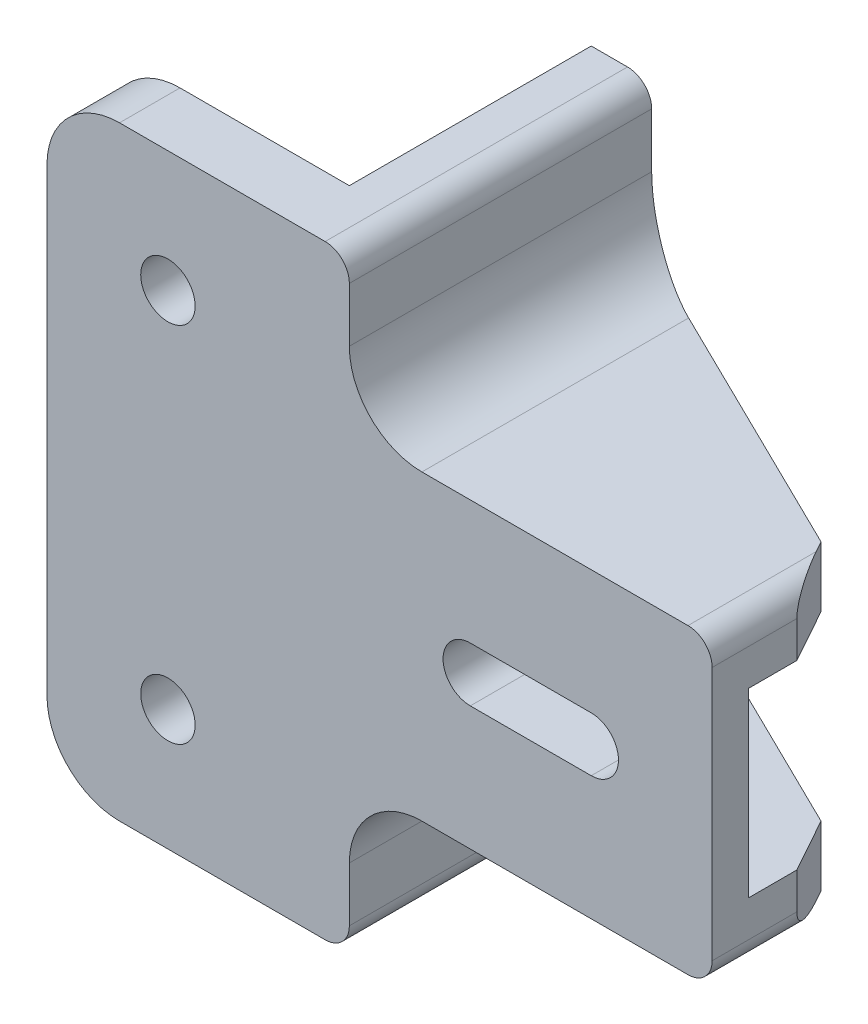
from build123d import *

# Parameters (mm, degrees)
BOSS_EXTRUDE1_DEPTH = 5
SKETCH2_R           = 2.25
CUT_EXTRUDE1_DEPTH  = 6
SKETCH3_W           = 5
SKETCH3_H           = 50
BOSS_EXTRUDE2_DEPTH = 20
SKETCH4_R           = 2.25
CUT_EXTRUDE2_DEPTH  = 36
SKETCH5_W           = 20
SKETCH5_H           = 5
BOSS_EXTRUDE3_DEPTH = 30
CUT_EXTRUDE3_DEPTH  = 38.5
FILLET1_R           = 6
CHAMFER1_SIZE       = 2
FILLET2_R           = 6
FILLET3_R           = 2


with BuildPart() as part:
    # Sketch1 → Boss-Extrude1 (new body)
    with BuildSketch(Plane.XY):
        Polygon((0, 25), (0, 0), (-30, 0), (-30, -12.5), (-55, -12.5), (-55, 37.5), (-30, 37.5), (-30, 25), align=None)
    extrude(amount=BOSS_EXTRUDE1_DEPTH)

    # Sketch2 → Cut-Extrude1 (cut, through all)
    with BuildSketch(Plane.XY.offset(5)):
        with Locations((-45, -2.5)):
            Circle(SKETCH2_R)
        with Locations((-45, 27.5)):
            Circle(SKETCH2_R)
        with BuildLine():
            Line((-10, 10.25), (-20, 10.25))
            ThreePointArc((-20, 10.25), (-22.25, 12.5), (-20, 14.75))
            Line((-20, 14.75), (-10, 14.75))
            ThreePointArc((-10, 14.75), (-7.75, 12.5), (-10, 10.25))
        make_face()
    extrude(amount=-CUT_EXTRUDE1_DEPTH, mode=Mode.SUBTRACT)

    # Sketch3 → Boss-Extrude2 (add)
    with BuildSketch(Plane(origin=(0, 0, 0), x_dir=(-1, 0, 0), z_dir=(0, 0, -1))):
        with Locations((32.5, 12.5)):
            Rectangle(SKETCH3_W, SKETCH3_H)
    extrude(amount=BOSS_EXTRUDE2_DEPTH)

    # Sketch4 → Cut-Extrude2 (cut, through all)
    with BuildSketch(Plane.ZY.offset(35)):
        with Locations((-10, 12.5)):
            Circle(SKETCH4_R)
    extrude(amount=-CUT_EXTRUDE2_DEPTH, mode=Mode.SUBTRACT)

    # Sketch5 → Boss-Extrude3 (add)
    with BuildSketch(Plane(origin=(0, 0, 0), x_dir=(0, 0, -1), z_dir=(1, 0, 0))):
        with Locations((10, 22.5)):
            Rectangle(SKETCH5_W, SKETCH5_H)
        with Locations((10, 2.5)):
            Rectangle(SKETCH5_W, SKETCH5_H)
    extrude(amount=-BOSS_EXTRUDE3_DEPTH)

    # Sketch6 → Cut-Extrude3 (cut, through all)
    with BuildSketch(Plane(origin=(0, 25, 0), x_dir=(1, 0, 0), z_dir=(0, 1, 0))):
        Polygon((-30, 20), (0, 20), (0, 2), (-2.5, 6.5), align=None)
    extrude(amount=-CUT_EXTRUDE3_DEPTH, mode=Mode.SUBTRACT)

    # Fillet1
    fillet1_edges = [part.edges().sort_by_distance(p)[0] for p in [
        (-30, 0, -7.5),
        (-30, 25, -7.5),
    ]]
    fillet(fillet1_edges, radius=FILLET1_R)

    # Chamfer1
    chamfer1_edges = [part.edges().sort_by_distance(p)[0] for p in [
        (-30, 12.5, 0),
        (0, 12.5, 0),
    ]]
    chamfer(chamfer1_edges, length=CHAMFER1_SIZE)

    # Fillet2
    fillet2_edges = [part.edges().sort_by_distance(p)[0] for p in [
        (-55, -12.5, 2.5),
        (-55, 37.5, 2.5),
    ]]
    fillet(fillet2_edges, radius=FILLET2_R)

    # Fillet3
    fillet3_edges = [part.edges().sort_by_distance(p)[0] for p in [
        (0, 25, 1.5),
        (0, 0, 1.5),
        (-30, -12.5, -7.5),
        (-30, 37.5, -7.5),
    ]]
    fillet(fillet3_edges, radius=FILLET3_R)


solid = part.part
